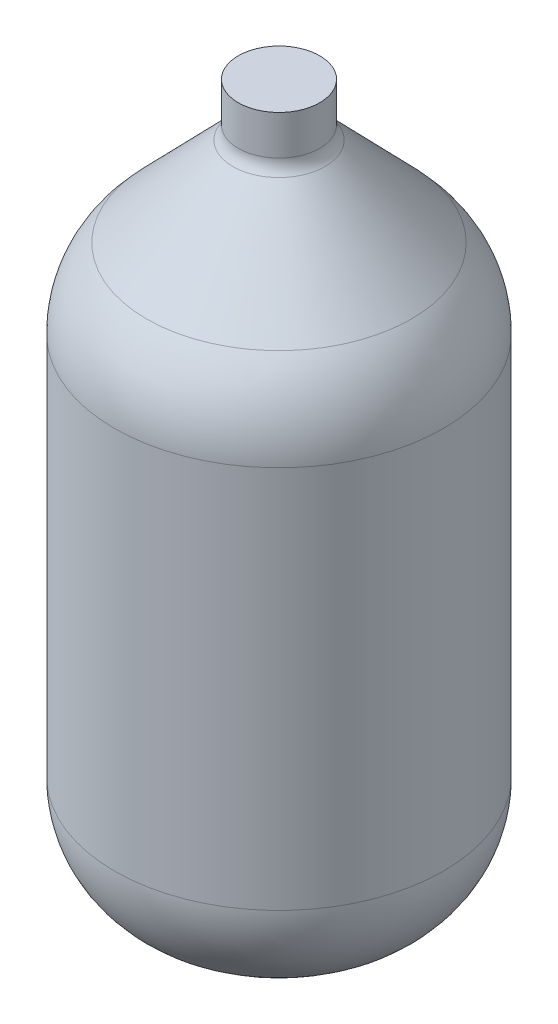
from build123d import *


with BuildPart() as part:
    # Sketch4 → Revolve3 (revolve)
    with BuildSketch(Plane(origin=(0, 0, 0), x_dir=(0, 0, -1), z_dir=(1, 0, 0))):
        with BuildLine():
            Line((55.372, 64.560899101), (55.372, -64.560899101))
            ThreePointArc((55.372, -64.560899101), (50.818345537, -82.623365742), (38.245873957, -96.36823491))
            Line((38.245873957, -96.36823491), (20.973873957, -107.757455094))
            ThreePointArc((20.973873957, -107.757455094), (10.948755767, -112.443060344), (0, -114.050119285))
            Line((0, -114.050119285), (0, 138.762295451))
            Line((0, 138.762295451), (13.716, 138.762295451))
            Line((13.716, 138.762295451), (13.716, 125.464611509))
            ThreePointArc((13.716, 125.464611509), (14.182171321, 123.076503456), (15.512239394, 121.039030831))
            Line((15.512239394, 121.039030831), (44.594563638, 91.114383171))
            ThreePointArc((44.594563638, 91.114383171), (52.574972075, 78.889547422), (55.372, 64.560899101))
        make_face()
    revolve(axis=Axis((0, 138.762295451, 0), (0, -1, 0)))


solid = part.part
